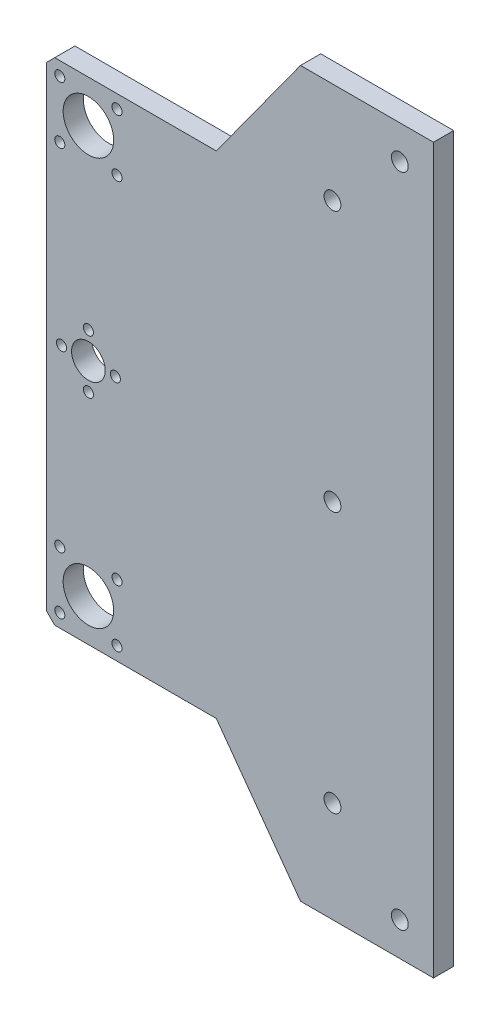
from build123d import *

# Parameters (mm, degrees)
ESBO_O1_R                = 1.499999648
ESBO_O1_R_2              = 1.500000298
ESBO_O1_R_3              = 7.49999945
ESBO_O1_R_4              = 1.49999992
ESBO_O1_R_5              = 2.500000663
ESBO_O1_R_6              = 2.499999944
ESBO_O1_R_7              = 1.500000264
ESBO_O1_R_8              = 2.499997616
ESBO_O1_R_9              = 2.499998574
ESBO_O1_R_10             = 2.500000277
ESBO_O1_R_11             = 1.500000402
ESBO_O1_R_12             = 1.500002802
ESBO_O1_R_13             = 1.500001991
ESBO_O1_R_14             = 5.000001307
ESBO_O1_R_15             = 1.500000261
RESSALTO_EXTRUS_O1_DEPTH = 6


with BuildPart() as part:
    # Esboço1 → Ressalto-extrusão1 (new body)
    with BuildSketch(Plane.XY):
        Polygon((-39.385000246, 159.55550476), (0.115000002, 159.55550476), (0.115000002, -55.444498231), (-39.384998091, -55.444498231), (-64.385000326, -20.944499718), (-112.38500214, -20.944499718), (-114.885002049, -18.444498377), (-114.885002049, 122.555504246), (-112.385001967, 125.055501899), (-64.385002481, 125.055501899), align=None)
        with Locations((-110.885001778, 0.055499999)):
            Circle(ESBO_O1_R, mode=Mode.SUBTRACT)
        with Locations((-93.885001436, 0.055499999)):
            Circle(ESBO_O1_R_2, mode=Mode.SUBTRACT)
        with Locations((-102.385001898, -8.444500463)):
            Circle(ESBO_O1_R_3, mode=Mode.SUBTRACT)
        with Locations((-110.885002127, -16.944500925)):
            Circle(ESBO_O1_R_4, mode=Mode.SUBTRACT)
        with Locations((-29.885004915, -25.444498593)):
            Circle(ESBO_O1_R_5, mode=Mode.SUBTRACT)
        with Locations((-9.885005362, -45.444498612)):
            Circle(ESBO_O1_R_6, mode=Mode.SUBTRACT)
        with Locations((-93.885002367, -16.944499062)):
            Circle(ESBO_O1_R_7, mode=Mode.SUBTRACT)
        with Locations((-29.88500119, 52.055502934)):
            Circle(ESBO_O1_R_8, mode=Mode.SUBTRACT)
        with Locations((-9.885001637, 149.555499358)):
            Circle(ESBO_O1_R_9, mode=Mode.SUBTRACT)
        with Locations((-29.88500119, 129.55550353)):
            Circle(ESBO_O1_R_10, mode=Mode.SUBTRACT)
        with Locations((-102.385000966, 60.055504246)):
            Circle(ESBO_O1_R_11, mode=Mode.SUBTRACT)
        with Locations((-94.385001518, 52.055502934)):
            Circle(ESBO_O1_R_12, mode=Mode.SUBTRACT)
        with Locations((-110.385000997, 52.055502934)):
            Circle(ESBO_O1_R_13, mode=Mode.SUBTRACT)
        with Locations((-102.385000966, 52.055502934)):
            Circle(ESBO_O1_R_14, mode=Mode.SUBTRACT)
        with Locations((-102.385000966, 44.055505348)):
            Circle(ESBO_O1_R_15, mode=Mode.SUBTRACT)
        with Locations((-93.885002367, 121.055504931)):
            Circle(ESBO_O1_R_7, mode=Mode.SUBTRACT)
        with Locations((-110.885002127, 121.055506794)):
            Circle(ESBO_O1_R_4, mode=Mode.SUBTRACT)
        with Locations((-102.385001898, 112.555506332)):
            Circle(ESBO_O1_R_3, mode=Mode.SUBTRACT)
        with Locations((-93.885001436, 104.05550587)):
            Circle(ESBO_O1_R_2, mode=Mode.SUBTRACT)
        with Locations((-110.885001778, 104.05550587)):
            Circle(ESBO_O1_R, mode=Mode.SUBTRACT)
    extrude(amount=RESSALTO_EXTRUS_O1_DEPTH)


solid = part.part
